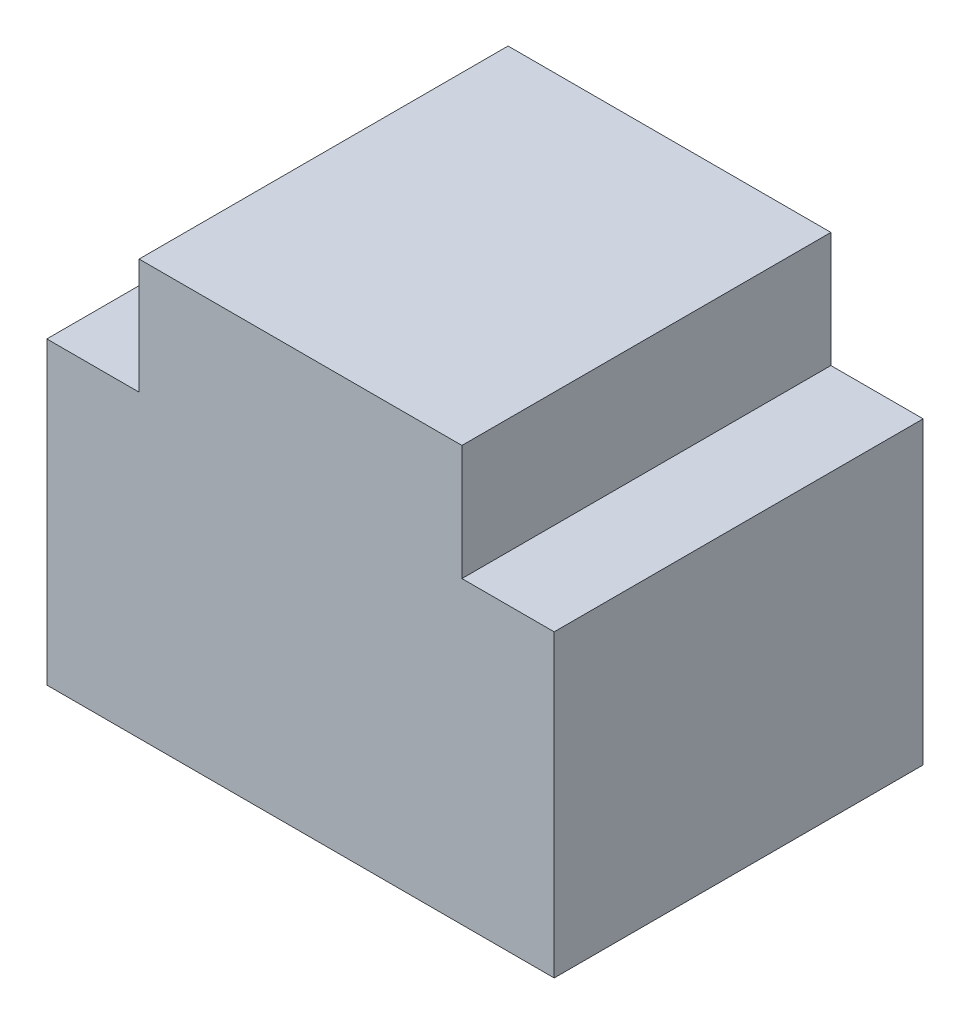
from build123d import *

# Parameters (mm, degrees)
BOSS_EXTRUDE1_DEPTH = 8


with BuildPart() as part:
    # Sketch1 → Boss-Extrude1 (new body)
    with BuildSketch(Plane.XY):
        Polygon((0, 0), (7, 0), (7, -2.5), (9, -2.5), (9, -9), (-2, -9), (-2, -2.5), (0, -2.5), align=None)
    extrude(amount=BOSS_EXTRUDE1_DEPTH)


solid = part.part
